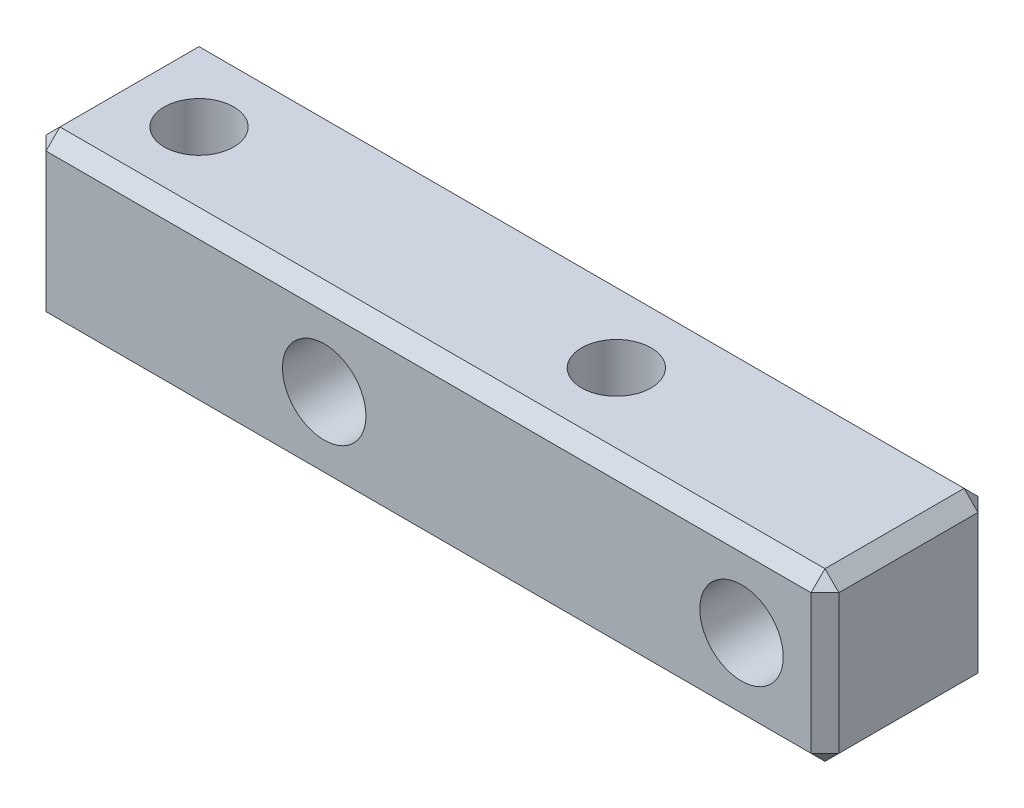
from build123d import *

# Parameters (mm, degrees)
SKETCH_2_W         = 28.5
SKETCH_2_H         = 6
SKETCH_2_R         = 1.5
EXTRUDE_1_DEPTH    = 3
HOLE_WIZARD_M3_2_D = 2.5
CHAMFER_1_SIZE     = 0.5


with BuildPart() as part:
    # 草图2 → 凸台-拉伸1 (new body, symmetric)
    with BuildSketch(Plane.XY):
        with Locations((-11.25, 0)):
            Rectangle(SKETCH_2_W, SKETCH_2_H)
        with Locations((-15, 0)):
            Circle(SKETCH_2_R, mode=Mode.SUBTRACT)
        Circle(SKETCH_2_R, mode=Mode.SUBTRACT)
    extrude(amount=EXTRUDE_1_DEPTH, both=True)

    # M3 螺纹孔2 (through all)
    with Locations(Plane(origin=(0, 3, 0), x_dir=(1, 0, 0), z_dir=(0, 1, 0))):
        with Locations((-7.5, 0), (-22.5, 0)):
            Hole(HOLE_WIZARD_M3_2_D / 2)

    # 倒角1
    chamfer_1_edges = [part.edges().sort_by_distance(p)[0] for p in [
        (-11.25, -3, 3),
        (3, 0, 3),
        (-11.25, 3, 3),
        (3, 0, -3),
        (-11.25, -3, -3),
        (-25.5, 0, -3),
        (-11.25, 3, -3),
        (-25.5, 0, 3),
        (3, 3, 0),
        (3, -3, 0),
        (-25.5, -3, 0),
        (-25.5, 3, 0),
    ]]
    chamfer(chamfer_1_edges, length=CHAMFER_1_SIZE)


solid = part.part
